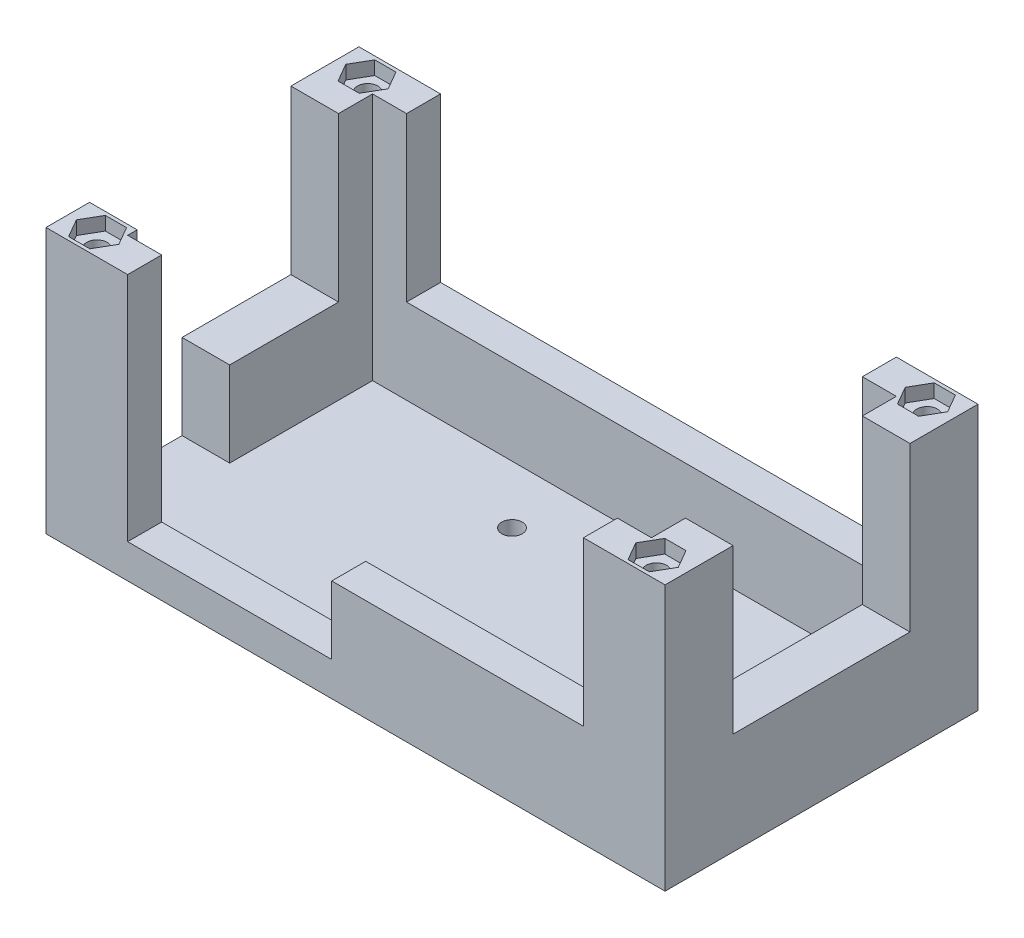
from build123d import *

# Parameters (mm, degrees)
BOSS_EXTRUDE7_DEPTH   = 39
BOSS_EXTRUDE7_2_DEPTH = 39
BOSS_EXTRUDE7_3_DEPTH = 39
BOSS_EXTRUDE7_4_DEPTH = 39
SKETCH1_11_R          = 1.5
BOSS_EXTRUDE8_DEPTH   = 2.5
SKETCH1_12_W          = 67
SKETCH1_12_H          = 5
SKETCH1_12_W_2        = 7
SKETCH1_12_H_2        = 26
BOSS_EXTRUDE9_DEPTH   = 15
SKETCH1_19_R          = 1.5
BOSS_EXTRUDE12_DEPTH  = 37
SKETCH1_20_R          = 1.5
BOSS_EXTRUDE13_DEPTH  = 15
SKETCH4_W             = 13.6
SKETCH4_H             = 36.5
CUT_EXTRUDE2_DEPTH    = 102.281785134
SKETCH5_W             = 30
SKETCH5_H             = 10
CUT_EXTRUDE4_DEPTH    = 15


with BuildPart() as part:
    # Sketch1 → Boss-Extrude7 (new body)
    with BuildSketch(Plane(origin=(0, 0, 0), x_dir=(1, 0, 0), z_dir=(0, 1, 0))):
        Polygon((5, 0), (0, 0), (0, 5), (-7, 5), (-7, -5), (5, -5), align=None)
        Polygon((-5.735382907, -1.8), (-4.17653718, 0.9), (-1.058845727, 0.9), (0.5, -1.8), (-1.058845727, -4.5), (-4.17653718, -4.5), align=None, mode=Mode.SUBTRACT)
    extrude(amount=BOSS_EXTRUDE7_DEPTH)



with BuildPart() as body_2:
    # Sketch1 → Boss-Extrude7 2 (new body)
    with BuildSketch(Plane(origin=(0, 0, 0), x_dir=(1, 0, 0), z_dir=(0, 1, 0))):
        Polygon((77, 0), (72, 0), (72, -5), (84, -5), (84, 5), (77, 5), align=None)
        Polygon((81.17653718, 0.9), (82.735382907, -1.8), (81.17653718, -4.5), (78.058845727, -4.5), (76.5, -1.8), (78.058845727, 0.9), align=None, mode=Mode.SUBTRACT)
    extrude(amount=BOSS_EXTRUDE7_2_DEPTH)


with BuildPart() as body_3:
    # Sketch1 → Boss-Extrude7 3 (new body)
    with BuildSketch(Plane(origin=(0, 0, 0), x_dir=(1, 0, 0), z_dir=(0, 1, 0))):
        Polygon((-7, 31), (0, 31), (0, 36), (5, 36), (5, 41), (-7, 41), align=None)
        Polygon((0.5, 37.8), (-1.058845727, 35.1), (-4.17653718, 35.1), (-5.735382907, 37.8), (-4.17653718, 40.5), (-1.058845727, 40.5), align=None, mode=Mode.SUBTRACT)
    extrude(amount=BOSS_EXTRUDE7_3_DEPTH)


with BuildPart() as body_4:
    # Sketch1 → Boss-Extrude7 4 (new body)
    with BuildSketch(Plane(origin=(0, 0, 0), x_dir=(1, 0, 0), z_dir=(0, 1, 0))):
        Polygon((77, 36), (77, 31), (84, 31), (84, 41), (72, 41), (72, 36), align=None)
        Polygon((82.735382907, 37.8), (81.17653718, 35.1), (78.058845727, 35.1), (76.5, 37.8), (78.058845727, 40.5), (81.17653718, 40.5), align=None, mode=Mode.SUBTRACT)
    extrude(amount=BOSS_EXTRUDE7_4_DEPTH)


    add(body_2.part)  # Boss-Extrude8 merges body 2

    add(body_3.part)  # Boss-Extrude8 merges body 3
    # Sketch1_11 → Boss-Extrude8 (add)
    with BuildSketch(Plane(origin=(0, 0, 0), x_dir=(1, 0, 0), z_dir=(0, 1, 0))):
        Polygon((0, 5), (0, 0), (5, 0), (72, 0), (77, 0), (77, 5), (77, 31), (77, 36), (72, 36), (5, 36), (0, 36), (0, 31), align=None)
        with Locations((29, 8.5)):
            Circle(SKETCH1_11_R, mode=Mode.SUBTRACT)
        with Locations((48, 8.5)):
            Circle(SKETCH1_11_R, mode=Mode.SUBTRACT)
        with Locations((29, 27.5)):
            Circle(SKETCH1_11_R, mode=Mode.SUBTRACT)
        with Locations((48, 27.5)):
            Circle(SKETCH1_11_R, mode=Mode.SUBTRACT)
    extrude(amount=BOSS_EXTRUDE8_DEPTH)

    # Sketch1_12 → Boss-Extrude9 (add)
    with BuildSketch(Plane(origin=(0, 0, 0), x_dir=(1, 0, 0), z_dir=(0, 1, 0))):
        with Locations((38.5, -2.5)):
            Rectangle(SKETCH1_12_W, SKETCH1_12_H)
        with Locations((-3.5, 18)):
            Rectangle(SKETCH1_12_W_2, SKETCH1_12_H_2)
        with Locations((80.5, 18)):
            Rectangle(SKETCH1_12_W_2, SKETCH1_12_H_2)
        with Locations((38.5, 38.5)):
            Rectangle(SKETCH1_12_W, SKETCH1_12_H)
    extrude(amount=BOSS_EXTRUDE9_DEPTH)


with BuildPart() as part_1:
    add(part.part)

    add(body_4.part)  # Boss-Extrude12 merges body 4
    # Sketch1_19 → Boss-Extrude12 (add)
    # profile 1 of 4: a face of its own
    with BuildSketch(Plane(origin=(0, 0, 0), x_dir=(1, 0, 0), z_dir=(0, 1, 0))):
        Polygon((-1.058845727, 0.9), (-4.17653718, 0.9), (-5.735382907, -1.8), (-4.17653718, -4.5), (-1.058845727, -4.5), (0.5, -1.8), align=None)
        with Locations((-2.617691454, -1.9)):
            Circle(SKETCH1_19_R, mode=Mode.SUBTRACT)
    # profile 2 of 4: a face of its own
    with BuildSketch(Plane(origin=(0, 0, 0), x_dir=(1, 0, 0), z_dir=(0, 1, 0))):
        Polygon((-4.17653718, 35.1), (-1.058845727, 35.1), (0.5, 37.8), (-1.058845727, 40.5), (-4.17653718, 40.5), (-5.735382907, 37.8), align=None)
        with Locations((-2.617691454, 37.9)):
            Circle(SKETCH1_19_R, mode=Mode.SUBTRACT)
    # profile 3 of 4: a face of its own
    with BuildSketch(Plane(origin=(0, 0, 0), x_dir=(1, 0, 0), z_dir=(0, 1, 0))):
        Polygon((81.17653718, -4.5), (82.735382907, -1.8), (81.17653718, 0.9), (78.058845727, 0.9), (76.5, -1.8), (78.058845727, -4.5), align=None)
        with Locations((79.617691454, -1.9)):
            Circle(SKETCH1_19_R, mode=Mode.SUBTRACT)
    # profile 4 of 4: a face of its own
    with BuildSketch(Plane(origin=(0, 0, 0), x_dir=(1, 0, 0), z_dir=(0, 1, 0))):
        Polygon((78.058845727, 35.1), (81.17653718, 35.1), (82.735382907, 37.8), (81.17653718, 40.5), (78.058845727, 40.5), (76.5, 37.8), align=None)
        with Locations((79.617691454, 37.9)):
            Circle(SKETCH1_19_R, mode=Mode.SUBTRACT)
    extrude(amount=BOSS_EXTRUDE12_DEPTH)

    # Sketch1_20 → Boss-Extrude13 (add)
    with BuildSketch(Plane(origin=(0, 0, 0), x_dir=(1, 0, 0), z_dir=(0, 1, 0))):
        with Locations((-2.617691454, 37.9)):
            Circle(SKETCH1_20_R)
        with Locations((-2.617691454, -1.9)):
            Circle(SKETCH1_20_R)
        with Locations((79.617691454, -1.9)):
            Circle(SKETCH1_20_R)
        with Locations((79.617691454, 37.9)):
            Circle(SKETCH1_20_R)
    extrude(amount=BOSS_EXTRUDE13_DEPTH)

    # Sketch4 → Cut-Extrude2 (cut, through all)
    with BuildSketch(Plane(origin=(0, 0, 0), x_dir=(0, 0, -1), z_dir=(1, 0, 0))):
        with Locations((8.2, 20.75)):
            Rectangle(SKETCH4_W, SKETCH4_H)
    extrude(amount=-CUT_EXTRUDE2_DEPTH, mode=Mode.SUBTRACT)

    # Sketch5 → Cut-Extrude4 (cut)
    with BuildSketch(Plane.XY.offset(5)):
        with Locations((20, 10)):
            Rectangle(SKETCH5_W, SKETCH5_H)
    extrude(amount=-CUT_EXTRUDE4_DEPTH, mode=Mode.SUBTRACT)


solid = part_1.part
